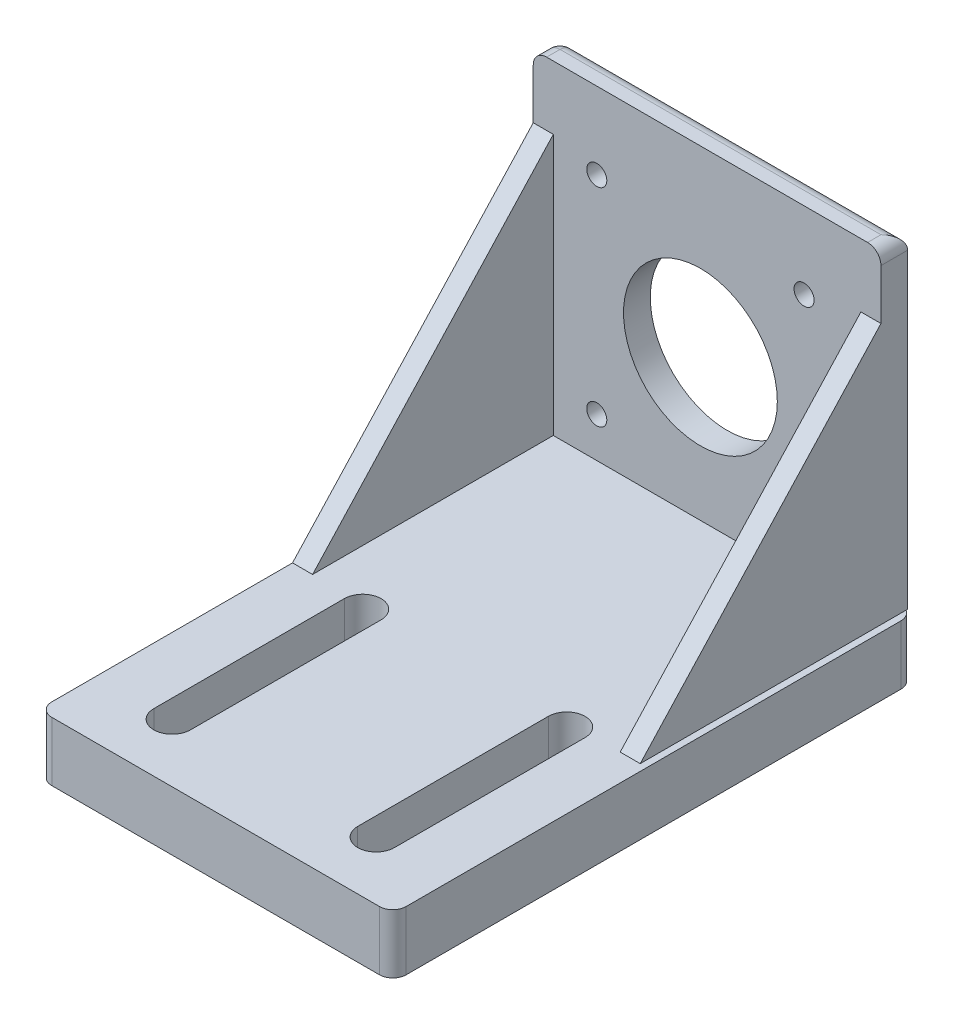
from build123d import *

# Parameters (mm, degrees)
SKETCH1_W               = 53
SKETCH1_H               = 78
BOSS_EXTRUDE1_DEPTH     = 8.85
FILLET2_R               = 2
CUT_EXTRUDE1_DEPTH      = 69.980595097
CUT_EXTRUDE1_DEPTH_BACK = 69.980595097
BOSS_EXTRUDE2_DEPTH     = 48.5
FILLET4_R               = 2
RIB7_REACH              = 96.942
SKETCH4_WALL_W          = 244.959830248
SKETCH4_WALL_H          = 3
RIB8_REACH              = 96.388
SKETCH6_WALL_W          = 243.850654762
SKETCH6_WALL_H          = 3
SKETCH7_R               = 11.5
SKETCH7_R_2             = 1.5
CUT_EXTRUDE2_DEPTH      = 103.611025236


with BuildPart() as part:
    # Sketch1 → Boss-Extrude1 (new body)
    with BuildSketch(Plane(origin=(0, 0, 0), x_dir=(1, 0, 0), z_dir=(0, 1, 0))):
        with Locations((-15.5, -15)):
            Rectangle(SKETCH1_W, SKETCH1_H)
    extrude(amount=BOSS_EXTRUDE1_DEPTH)

    # Fillet2
    fillet2_edges = [part.edges().sort_by_distance(p)[0] for p in [
        (-42, 4.425, -24),
        (11, 4.425, -24),
        (11, 4.425, 54),
        (-42, 4.425, 54),
    ]]
    fillet(fillet2_edges, radius=FILLET2_R)

    # Sketch2 → Cut-Extrude1 (cut, two sides)
    with BuildSketch(Plane(origin=(0, 8.85, 0), x_dir=(1, 0, 0), z_dir=(0, 1, 0))) as cut_extrude1_sk:
        with BuildLine():
            Line((-33.5, -16.75), (-33.5, -45.25))
            ThreePointArc((-33.5, -45.25), (-30.749999997, -48), (-28, -45.249999994))
            Line((-28, -45.249999994), (-28, -16.75))
            ThreePointArc((-28, -16.75), (-30.75, -14), (-33.5, -16.75))
        make_face()
        with BuildLine():
            Line((2.5, -16.75), (2.5, -45.25))
            ThreePointArc((2.5, -45.25), (-0.250000003, -48), (-3, -45.249999994))
            Line((-3, -45.249999994), (-3, -16.75))
            ThreePointArc((-3, -16.75), (-0.25, -14), (2.5, -16.75))
        make_face()
    extrude(amount=CUT_EXTRUDE1_DEPTH, mode=Mode.SUBTRACT)
    extrude(cut_extrude1_sk.sketch, amount=-CUT_EXTRUDE1_DEPTH_BACK, mode=Mode.SUBTRACT)

    # Sketch3 → Boss-Extrude2 (add)
    with BuildSketch(Plane(origin=(0, 8.85, 0), x_dir=(1, 0, 0), z_dir=(0, 1, 0))):
        with BuildLine():
            Line((-42, 20), (10, 20))
            Line((10, 20), (10, 24))
            Line((10, 24), (-40, 24))
            ThreePointArc((-40, 24), (-41.414213562, 23.414213562), (-42, 22))
            Line((-42, 22), (-42, 20))
        make_face()
    extrude(amount=BOSS_EXTRUDE2_DEPTH)

    # Fillet4
    fillet4_edges = [part.edges().sort_by_distance(p)[0] for p in [
        (-42, 57.35, -21),
        (10, 57.35, -22),
        (-15, 57.35, -24),
        (-41.414213562, 57.35, -23.414213562),
    ]]
    fillet(fillet4_edges, radius=FILLET4_R)

    # Sketch4 wall → Rib7 (add, up to next)
    with BuildSketch(Plane(origin=(-42, 28.35, -2), x_dir=(0, 0.734803444627, -0.678280102733), z_dir=(0, -0.678280102733, -0.734803444627)), mode=Mode.PRIVATE) as rib7_sk1:
        with Locations((0, 1.5)):
            Rectangle(SKETCH4_WALL_W, SKETCH4_WALL_H)
    rib7_tool1 = extrude(rib7_sk1.sketch, amount=RIB7_REACH, mode=Mode.PRIVATE) - part.part
    add(rib7_tool1.solids().sort_by_distance((-42, 28.35, -2))[0])

    # Sketch6 wall → Rib8 (add, up to next)
    with BuildSketch(Plane(origin=(10, 28.35, -2), x_dir=(0, -0.734803444627, 0.678280102733), z_dir=(0, -0.678280102733, -0.734803444627)), mode=Mode.PRIVATE) as rib8_sk1:
        with Locations((0, 1.5)):
            Rectangle(SKETCH6_WALL_W, SKETCH6_WALL_H)
    rib8_tool1 = extrude(rib8_sk1.sketch, amount=RIB8_REACH, mode=Mode.PRIVATE) - part.part
    add(rib8_tool1.solids().sort_by_distance((10, 28.35, -2))[0])

    # Sketch7 → Cut-Extrude2 (cut, through all)
    with BuildSketch(Plane.XY.offset(-20)):
        with Locations((-17, 30)):
            Circle(SKETCH7_R)
        with Locations((-32.5, 45.85)):
            Circle(SKETCH7_R_2)
        with Locations((-32.5, 14.85)):
            Circle(SKETCH7_R_2)
        with Locations(Location((-1.5, 14.85, 0), (0, 0, 180))):
            Circle(SKETCH7_R_2)
        with Locations(Location((-1.5, 45.85, 0), (0, 0, 180))):
            Circle(SKETCH7_R_2)
    extrude(amount=-CUT_EXTRUDE2_DEPTH, mode=Mode.SUBTRACT)


solid = part.part
